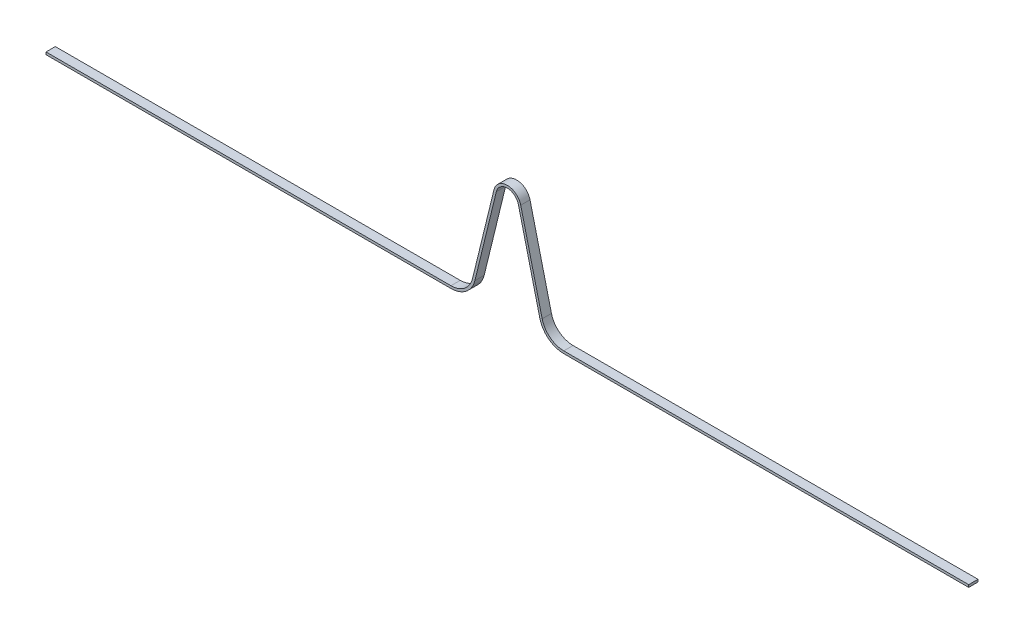
from build123d import *

# Parameters (mm, degrees)
EXTRUDE_THIN1_DEPTH = 2.5


with BuildPart() as part:
    # Sketch1 → Extrude-Thin1 (new body, symmetric)
    with BuildSketch(Plane.XY):
        with BuildLine():
            Line((-248, -54.5), (-30.32, -54.5))
            ThreePointArc((-30.32, -54.5), (-22.941113788, -51.949709478), (-18.71173445, -45.387370423))
            Line((-18.71173445, -45.387370423), (-7.188382014, 1.75703273))
            ThreePointArc((-7.188382014, 1.75703273), (0, 7.4), (7.188382014, 1.75703273))
            Line((7.188382014, 1.75703273), (18.71173445, -45.387370423))
            ThreePointArc((18.71173445, -45.387370423), (22.941113788, -51.949709478), (30.32, -54.5))
            Line((30.32, -54.5), (248, -54.5))
            Line((248, -54.5), (248, -55.8))
            Line((248, -55.8), (30.32, -55.8))
            ThreePointArc((30.32, -55.8), (22.138389765, -52.972272016), (17.448910582, -45.696038335))
            Line((17.448910582, -45.696038335), (5.925558147, 1.448364818))
            ThreePointArc((5.925558147, 1.448364818), (0, 6.1), (-5.925558147, 1.448364818))
            Line((-5.925558147, 1.448364818), (-17.448910582, -45.696038335))
            ThreePointArc((-17.448910582, -45.696038335), (-22.138389765, -52.972272016), (-30.32, -55.8))
            Line((-30.32, -55.8), (-248, -55.8))
            Line((-248, -55.8), (-248, -54.5))
        make_face()
    extrude(amount=EXTRUDE_THIN1_DEPTH, both=True)


solid = part.part
